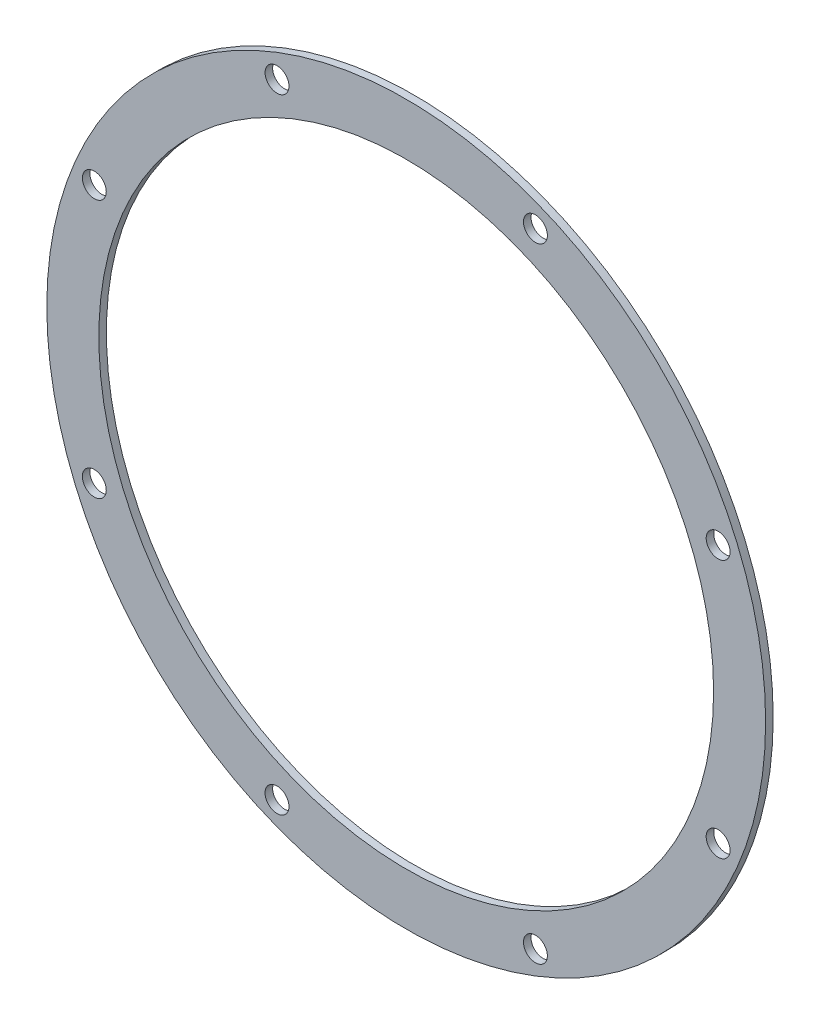
from build123d import *

# Parameters (mm, degrees)
SKETCH1_R                      = 76
SKETCH1_R_2                    = 65
BOSS_EXTRUDE1_DEPTH            = 1.6
F_8_0_199_DIAMETER_HOLE1_D     = 5.0546
F_8_0_199_DIAMETER_HOLE1_DEPTH = 8.481444958
F_8_0_199_DIAMETER_HOLE1_TIP   = 1.518555042


with BuildPart() as part:
    # Sketch1 → Boss-Extrude1 (new body)
    with BuildSketch(Plane.XY):
        Circle(SKETCH1_R)
        Circle(SKETCH1_R_2, mode=Mode.SUBTRACT)
    extrude(amount=BOSS_EXTRUDE1_DEPTH)

    # #8 (0.199) Diameter Hole1
    with Locations(Plane(origin=(-27.318507381, 65.952711024, 1.6), x_dir=(1, 0, 0), z_dir=(0, 0, 1))):
        with Locations((0, 0), (54.637014762, 0), (93.271218405, -38.634203643), (93.271218405, -93.271218405), (54.637014762, -131.905422048), (0, -131.905422048), (-38.634203643, -93.271218405), (-38.634203643, -38.634203643)):
            Hole(F_8_0_199_DIAMETER_HOLE1_D / 2, depth=F_8_0_199_DIAMETER_HOLE1_DEPTH)
            with Locations((0, 0, -(F_8_0_199_DIAMETER_HOLE1_DEPTH + F_8_0_199_DIAMETER_HOLE1_TIP / 2))):  # 118° drill point
                Cone(0, F_8_0_199_DIAMETER_HOLE1_D / 2, F_8_0_199_DIAMETER_HOLE1_TIP, mode=Mode.SUBTRACT)


solid = part.part
